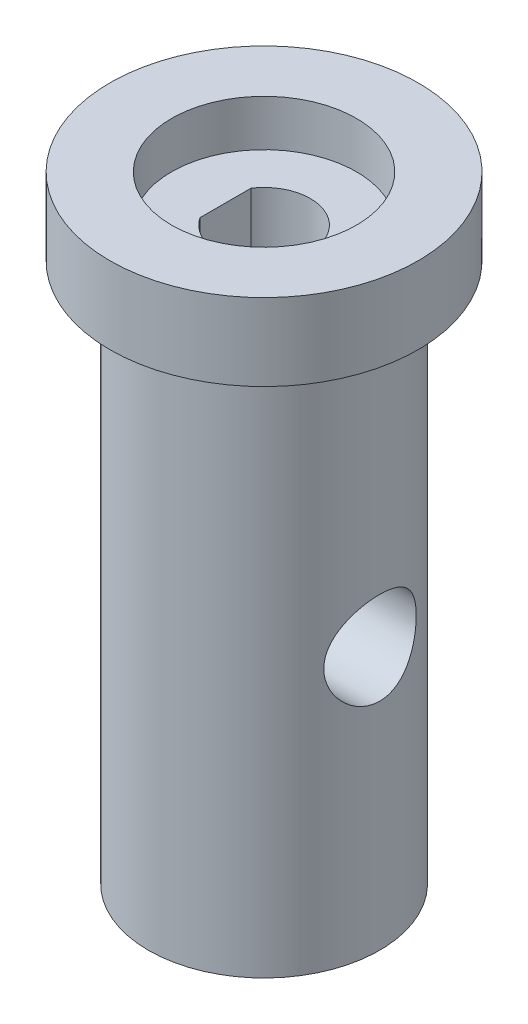
from build123d import *

# Parameters (mm, degrees)
SKETCH1_R                   = 10
METALSTOCK_DEPTH            = 40
EXTERIORLATHE_START         = -5
SKETCH2_OUTSIDE_W           = 31.798
SKETCH2_OUTSIDE_H           = 31.798
SKETCH2_OUTSIDE_R           = 7.5
EXTERIORLATHE_DEPTH         = 35
SKETCH6_R                   = 3
SHAFTHOLE_FOR_GEARBOX_DEPTH = 41
SKETCH7_W                   = 2
SKETCH7_H                   = 6
KEY_FOR_GEARBOX_DEPTH       = 12
SKETCH8_R                   = 3
SIDESCREWHOLE_DEPTH         = 11
SIDESCREWHOLE_DEPTH_BACK    = 11
SKETCH9_R                   = 6
GEARBOXCOUNTERSINK_DEPTH    = 3


with BuildPart() as part:
    # Sketch1 → MetalStock (new body)
    with BuildSketch(Plane(origin=(0, 0, 0), x_dir=(1, 0, 0), z_dir=(0, 1, 0))):
        Circle(SKETCH1_R)
    extrude(amount=-METALSTOCK_DEPTH)

    # Sketch2 outside → ExteriorLathe (cut)
    with BuildSketch(Plane(origin=(0, 0, 0), x_dir=(1, 0, 0), z_dir=(0, 1, 0)).offset(EXTERIORLATHE_START)):
        Rectangle(SKETCH2_OUTSIDE_W, SKETCH2_OUTSIDE_H)
        Circle(SKETCH2_OUTSIDE_R, mode=Mode.SUBTRACT)
    extrude(amount=-EXTERIORLATHE_DEPTH, mode=Mode.SUBTRACT)

    # Sketch6 → ShaftHole for Gearbox (cut, through all)
    with BuildSketch(Plane(origin=(0, 0, 0), x_dir=(1, 0, 0), z_dir=(0, 1, 0))):
        Circle(SKETCH6_R)
    extrude(amount=-SHAFTHOLE_FOR_GEARBOX_DEPTH, mode=Mode.SUBTRACT)

    # Sketch7 → Key for Gearbox (add)
    with BuildSketch(Plane(origin=(0, 0, 0), x_dir=(1, 0, 0), z_dir=(0, 1, 0))):
        with Locations((-3.5, 0)):
            Rectangle(SKETCH7_W, SKETCH7_H)
    extrude(amount=-KEY_FOR_GEARBOX_DEPTH)

    # Sketch8 → SideScrewHole (cut, two sides)
    with BuildSketch(Plane(origin=(0, 0, 0), x_dir=(0, 0, -1), z_dir=(1, 0, 0))) as sidescrewhole_sk:
        with Locations((0, -23)):
            Circle(SKETCH8_R)
    extrude(amount=SIDESCREWHOLE_DEPTH, mode=Mode.SUBTRACT)
    extrude(sidescrewhole_sk.sketch, amount=-SIDESCREWHOLE_DEPTH_BACK, mode=Mode.SUBTRACT)

    # Sketch9 → GearboxCounterSink (cut)
    with BuildSketch(Plane(origin=(0, 0, 0), x_dir=(1, 0, 0), z_dir=(0, 1, 0))):
        Circle(SKETCH9_R)
    extrude(amount=-GEARBOXCOUNTERSINK_DEPTH, mode=Mode.SUBTRACT)


solid = part.part
